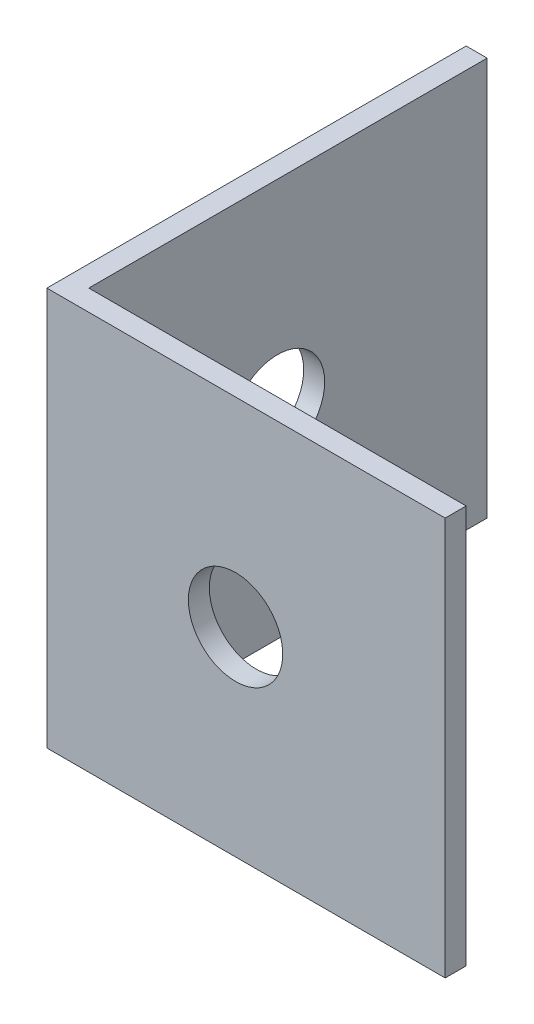
from build123d import *

# Parameters (mm, degrees)
EXTRUDE_1_DEPTH     = 19
SKETCH_2_W          = 1
SKETCH_2_H          = 19
CUT_EXTRUDE_1_DEPTH = 1
SKETCH_3_R          = 2.25
CUT_EXTRUDE_2_DEPTH = 2
SKETCH_4_R          = 2.25
CUT_EXTRUDE_3_DEPTH = 2


with BuildPart() as part:
    # Эскиз1 → Бобышка-Вытянуть1 (new body)
    with BuildSketch(Plane(origin=(0, 0, 0), x_dir=(1, 0, 0), z_dir=(0, 1, 0))):
        Polygon((0, 0), (0, 20), (1, 20), (1, 1), (20, 1), (20, 0), align=None)
    extrude(amount=EXTRUDE_1_DEPTH)

    # Эскиз2 → Вырез-Вытянуть1 (cut)
    with BuildSketch(Plane(origin=(20, 0, 0), x_dir=(0, 0, -1), z_dir=(1, 0, 0))):
        with Locations((0.5, 9.5)):
            Rectangle(SKETCH_2_W, SKETCH_2_H)
    extrude(amount=-CUT_EXTRUDE_1_DEPTH, mode=Mode.SUBTRACT)

    # Эскиз3 → Вырез-Вытянуть2 (cut, through all)
    with BuildSketch(Plane(origin=(0, 0, -1), x_dir=(-1, 0, 0), z_dir=(0, 0, -1))):
        with Locations((-9, 9.5)):
            Circle(SKETCH_3_R)
    extrude(amount=-CUT_EXTRUDE_2_DEPTH, mode=Mode.SUBTRACT)

    # Эскиз4 → Вырез-Вытянуть3 (cut, through all)
    with BuildSketch(Plane(origin=(1, 0, 0), x_dir=(0, 0, -1), z_dir=(1, 0, 0))):
        with Locations((10, 9.5)):
            Circle(SKETCH_4_R)
    extrude(amount=-CUT_EXTRUDE_3_DEPTH, mode=Mode.SUBTRACT)


solid = part.part
